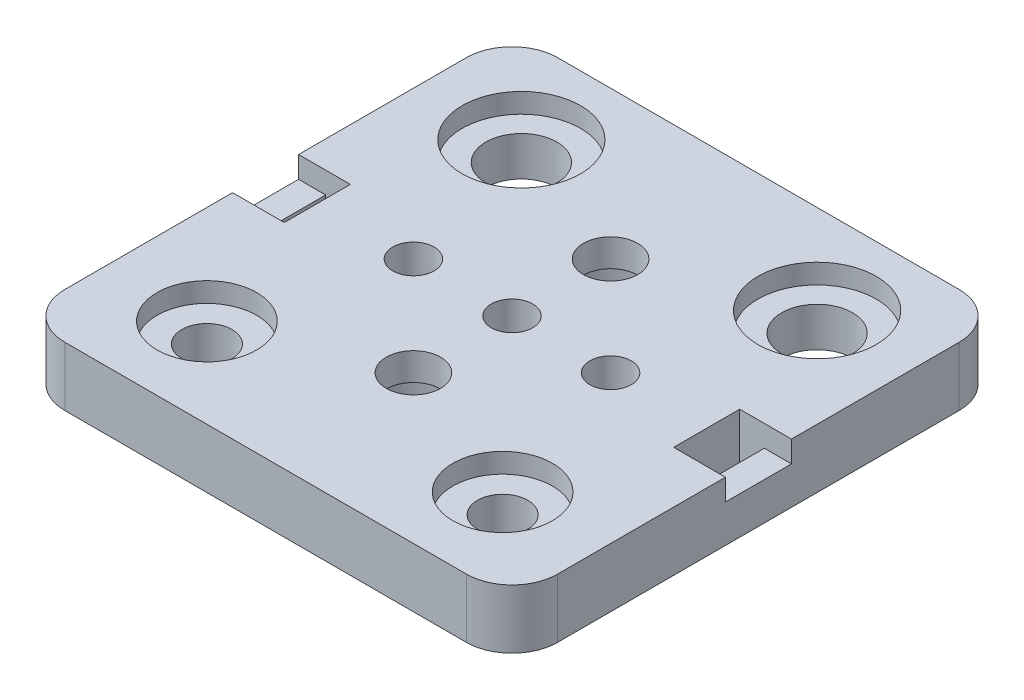
from build123d import *

# Parameters (mm, degrees)
SKETCH1_R                      = 3.6
SKETCH1_R_2                    = 2.55
BOSS_EXTRUDE1_DEPTH            = 6
M5X0_8_TAPPED_HOLE1_D          = 4.2
SKETCH2_R                      = 6
SKETCH2_R_2                    = 5.05
CUT_EXTRUDE1_DEPTH             = 2
SKETCH5_W                      = 5.25
SKETCH5_H                      = 6.7
CUT_EXTRUDE2_DEPTH             = 2.18
SKETCH6_W                      = 2.5
SKETCH6_H                      = 6.7
CUT_EXTRUDE3_DEPTH             = 4.82
CBORE_FOR_M5_SHCS1_D           = 5.5
CBORE_FOR_M5_SHCS1_CBORE_D     = 10
CBORE_FOR_M5_SHCS1_CBORE_DEPTH = 3.2


with BuildPart() as part:
    # Sketch1 → Boss-Extrude1 (new body)
    with BuildSketch(Plane(origin=(0, 0, 0), x_dir=(1, 0, 0), z_dir=(0, 1, 0))):
        with BuildLine():
            Line((20.365, -25), (-20.365, -25))
            ThreePointArc((-20.365, -25), (-23.642439931, -23.642439931), (-25, -20.365))
            Line((-25, -20.365), (-25, 20.365))
            ThreePointArc((-25, 20.365), (-23.642439931, 23.642439931), (-20.365, 25))
            Line((-20.365, 25), (20.365, 25))
            ThreePointArc((20.365, 25), (23.642439931, 23.642439931), (25, 20.365))
            Line((25, 20.365), (25, -20.365))
            ThreePointArc((25, -20.365), (23.642439931, -23.642439931), (20.365, -25))
        make_face()
        with Locations((-15, 15.95)):
            Circle(SKETCH1_R, mode=Mode.SUBTRACT)
        with Locations((15, 15.95)):
            Circle(SKETCH1_R, mode=Mode.SUBTRACT)
        with Locations((15, -15.95)):
            Circle(SKETCH1_R_2, mode=Mode.SUBTRACT)
        with Locations((-15, -15.95)):
            Circle(SKETCH1_R_2, mode=Mode.SUBTRACT)
    extrude(amount=BOSS_EXTRUDE1_DEPTH)

    # M5x0.8 Tapped Hole1 (through all)
    with Locations(Plane(origin=(0, 6, 0), x_dir=(1, 0, 0), z_dir=(0, 1, 0))):
        with Locations((0, 10), (-10, 0), (0, 0), (0, -10), (10, 0)):
            Hole(M5X0_8_TAPPED_HOLE1_D / 2)

    # Sketch2 → Cut-Extrude1 (cut)
    with BuildSketch(Plane(origin=(0, 6, 0), x_dir=(1, 0, 0), z_dir=(0, 1, 0))):
        with Locations((-15, 15.95)):
            Circle(SKETCH2_R)
        with Locations((15, 15.95)):
            Circle(SKETCH2_R)
        with Locations((15, -15.95)):
            Circle(SKETCH2_R_2)
        with Locations((-15, -15.95)):
            Circle(SKETCH2_R_2)
    extrude(amount=-CUT_EXTRUDE1_DEPTH, mode=Mode.SUBTRACT)

    # Sketch5 → Cut-Extrude2 (cut)
    with BuildSketch(Plane(origin=(0, 6, 0), x_dir=(1, 0, 0), z_dir=(0, 1, 0))):
        with Locations((-22.375, 0)):
            Rectangle(SKETCH5_W, SKETCH5_H)
        with Locations((22.375, 0)):
            Rectangle(SKETCH5_W, SKETCH5_H)
    extrude(amount=-CUT_EXTRUDE2_DEPTH, mode=Mode.SUBTRACT)

    # Sketch6 → Cut-Extrude3 (cut, through all)
    with BuildSketch(Plane(origin=(0, 3.82, 0), x_dir=(1, 0, 0), z_dir=(0, 1, 0))):
        with Locations((-21, 0)):
            Rectangle(SKETCH6_W, SKETCH6_H)
        with Locations((21, 0)):
            Rectangle(SKETCH6_W, SKETCH6_H)
    extrude(amount=-CUT_EXTRUDE3_DEPTH, mode=Mode.SUBTRACT)

    # CBORE for M5 SHCS1 (through all)
    with Locations(Plane(origin=(0, 0, 0), x_dir=(-1, 0, 0), z_dir=(0, -1, 0))):
        with Locations((0, 10), (0, -10)):
            CounterBoreHole(CBORE_FOR_M5_SHCS1_D / 2, CBORE_FOR_M5_SHCS1_CBORE_D / 2, CBORE_FOR_M5_SHCS1_CBORE_DEPTH)


solid = part.part
